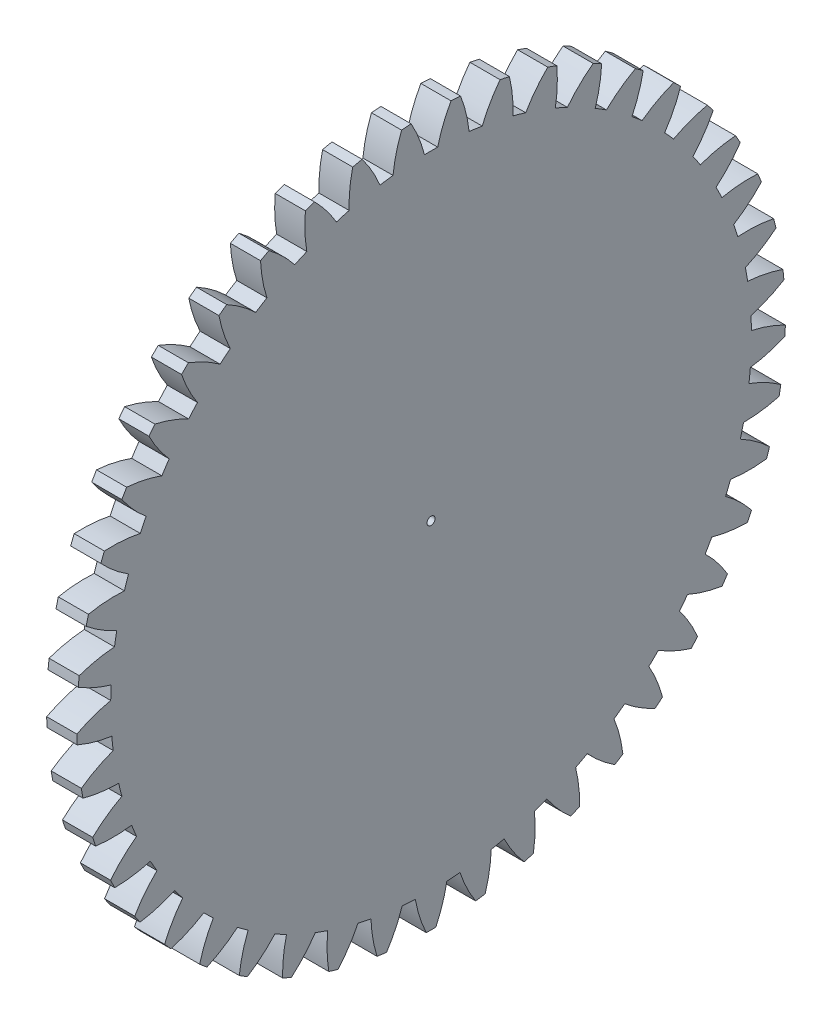
from build123d import *

# Parameters (mm, degrees)
BASPROSKE_W     = 3
BASPROSKE_H     = 35.25
TOOTHCUT_DEPTH  = 50.941215444
TEETHCUTS_COUNT = 45
TEETHCUTS_ANGLE = 352
BORSKE_R        = 0.4
BORE_DEPTH      = 50.0000508


with BuildPart() as part:
    # BasProSke → Base-Revolve (revolve)
    with BuildSketch(Plane(origin=(0, 0, 0), x_dir=(1, 0, 0), z_dir=(0, 1, 0)), mode=Mode.PRIVATE) as base_revolve_sk:
        with Locations((1.5, 17.625)):
            Rectangle(BASPROSKE_W, BASPROSKE_H)
    revolve(base_revolve_sk.sketch.rotate(Axis((-10, 0, 0), (1, 0, 0)), 180), axis=Axis((-10, 0, 0), (1, 0, 0)))

    # TooCutSke → ToothCut (cut, through all)
    with BuildSketch(Plane(origin=(0, 0, 0), x_dir=(0, 0, -1), z_dir=(1, 0, 0))):
        with BuildLine():
            ThreePointArc((0.65740255, 31.867219802), (0, 31.874), (-0.65740255, 31.867219802))
            ThreePointArc((-0.65740255, 31.867219802), (-1.214536483, 33.587992782), (-1.996699677, 35.218844892))
            ThreePointArc((-1.996699677, 35.218844892), (0, 35.2754), (1.996699677, 35.218844892))
            ThreePointArc((1.996699677, 35.218844892), (1.214536483, 33.587992782), (0.65740255, 31.867219802))
        make_face()
    toothcut = extrude(amount=TOOTHCUT_DEPTH, mode=Mode.SUBTRACT)

    # TeethCuts: ToothCut ×45 about axis
    teethcuts_axis = Axis((-10, 0, 0), (1, 0, 0))
    for i in range(1, TEETHCUTS_COUNT):
        add(toothcut.rotate(teethcuts_axis, i * TEETHCUTS_ANGLE / (TEETHCUTS_COUNT - 1)), mode=Mode.SUBTRACT)

    # BorSke → Bore (cut, symmetric)
    with BuildSketch(Plane(origin=(0, 0, 0), x_dir=(0, 0, -1), z_dir=(1, 0, 0))):
        with Locations(Location((0, 0, 0), (0, 0, 180))):
            Circle(BORSKE_R)
    extrude(amount=BORE_DEPTH, both=True, mode=Mode.SUBTRACT)


solid = part.part
